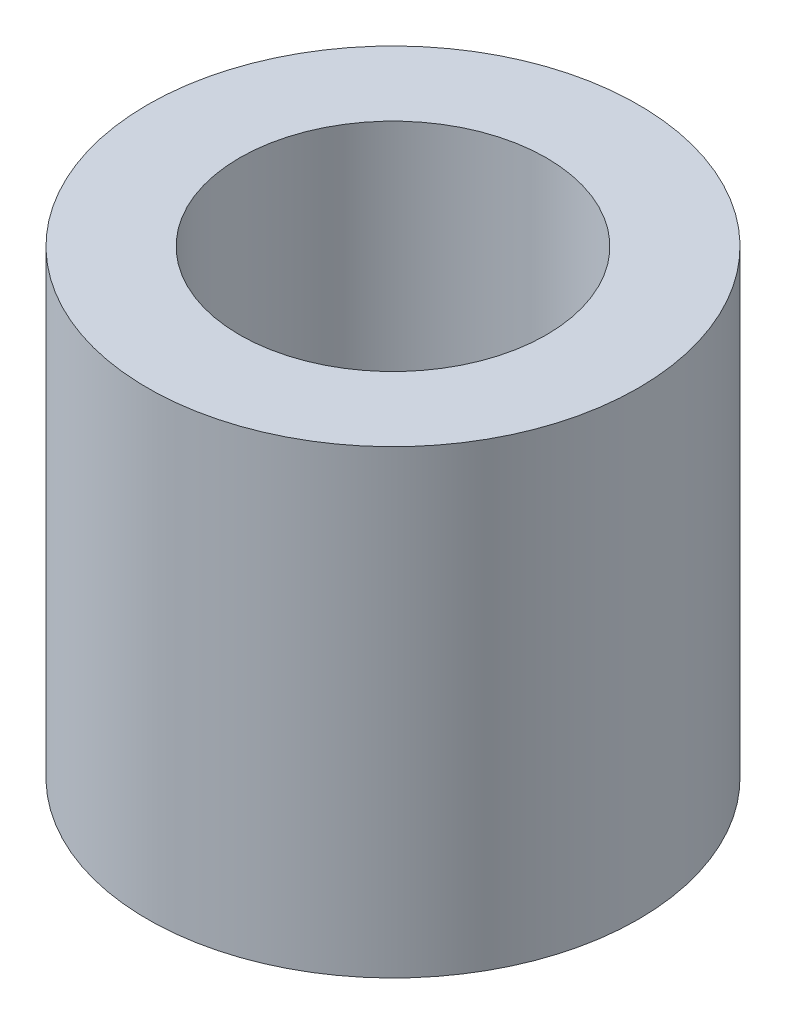
from build123d import *

# Parameters (mm, degrees)
SKETCH_1_R      = 8
SKETCH_1_R_2    = 5
EXTRUDE_1_DEPTH = 15


with BuildPart() as part:
    # Эскиз1 → Вытянуть-Тонкостенный1 (new body)
    with BuildSketch(Plane(origin=(0, 0, 0), x_dir=(1, 0, 0), z_dir=(0, 1, 0))):
        Circle(SKETCH_1_R)
        Circle(SKETCH_1_R_2, mode=Mode.SUBTRACT)
    extrude(amount=EXTRUDE_1_DEPTH)


solid = part.part
